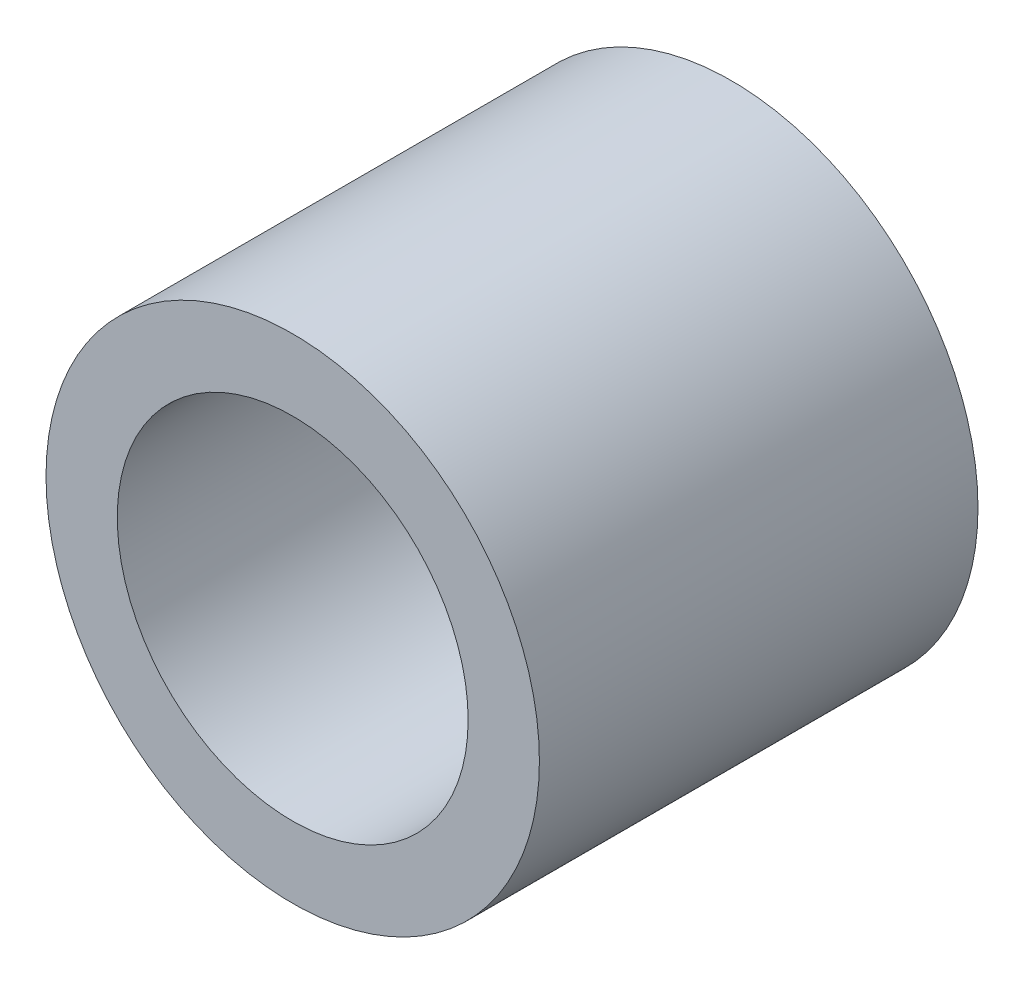
from build123d import *

# Parameters (mm, degrees)
SKETCH1_R      = 2.25
SKETCH1_R_2    = 1.6
EXTRUDE1_DEPTH = 2


with BuildPart() as part:
    # Sketch1 → Extrude1 (new body, symmetric)
    with BuildSketch(Plane.XY):
        Circle(SKETCH1_R)
        Circle(SKETCH1_R_2, mode=Mode.SUBTRACT)
    extrude(amount=EXTRUDE1_DEPTH, both=True)


solid = part.part
